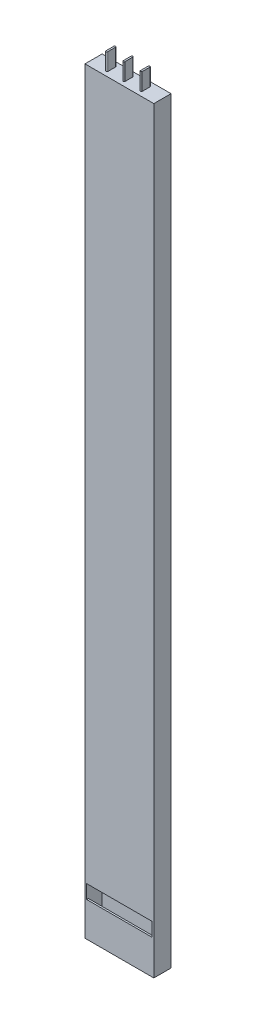
from build123d import *

# Parameters (mm, degrees)
SKETCH2_W           = 40
SKETCH2_H           = 10
BOSS_EXTRUDE2_DEPTH = 440
SKETCH3_W           = 38
SKETCH3_H           = 8
CUT_EXTRUDE1_DEPTH  = 438
BOSS_EXTRUDE4_DEPTH = 10
LPATTERN2_COUNT     = 3
LPATTERN2_PITCH     = 10
SKETCH5_W           = 38
SKETCH5_H           = 8
BOSS_EXTRUDE5_DEPTH = 12
CUT_EXTRUDE2_DEPTH  = 11
LPATTERN3_COUNT     = 3
LPATTERN3_PITCH     = 10
SKETCH7_W           = 38
SKETCH7_H           = 8
CUT_EXTRUDE3_DEPTH  = 5


with BuildPart() as part:
    # Sketch2 → Boss-Extrude2 (new body)
    with BuildSketch(Plane(origin=(0, 0, 0), x_dir=(1, 0, 0), z_dir=(0, 1, 0))):
        Rectangle(SKETCH2_W, SKETCH2_H)
    extrude(amount=BOSS_EXTRUDE2_DEPTH)

    # Sketch3 → Cut-Extrude1 (cut)
    with BuildSketch(Plane(origin=(0, 0, 0), x_dir=(1, 0, 0), z_dir=(0, 1, 0))):
        Rectangle(SKETCH3_W, SKETCH3_H)
    extrude(amount=CUT_EXTRUDE1_DEPTH, mode=Mode.SUBTRACT)

    # Sketch4 → Boss-Extrude4 (add)
    with BuildSketch(Plane(origin=(0, 440, 0), x_dir=(1, 0, 0), z_dir=(0, 1, 0))):
        with BuildLine():
            Line((-10.5, -2.25), (-10.5, 2.25))
            ThreePointArc((-10.5, 2.25), (-10, 2.75), (-9.5, 2.25))
            Line((-9.5, 2.25), (-9.5, -2.25))
            ThreePointArc((-9.5, -2.25), (-10, -2.75), (-10.5, -2.25))
        make_face()
    boss_extrude4 = extrude(amount=BOSS_EXTRUDE4_DEPTH)

    # LPattern2: Boss-Extrude4 ×3
    with Locations(*[(i * LPATTERN2_PITCH, 0, 0) for i in range(1, LPATTERN2_COUNT)]):
        add(boss_extrude4)

    # Sketch5 → Boss-Extrude5 (add)
    with BuildSketch(Plane(origin=(0, 0, 0), x_dir=(-1, 0, 0), z_dir=(0, -1, 0))):
        Rectangle(SKETCH5_W, SKETCH5_H)
    extrude(amount=-BOSS_EXTRUDE5_DEPTH)

    # Sketch6 → Cut-Extrude2 (cut)
    with BuildSketch(Plane.XZ):
        with BuildLine():
            Line((10.5, 2.25), (10.5, -2.25))
            ThreePointArc((10.5, -2.25), (10, -2.75), (9.5, -2.25))
            Line((9.5, -2.25), (9.5, 2.25))
            ThreePointArc((9.5, 2.25), (10, 2.75), (10.5, 2.25))
        make_face()
    cut_extrude2 = extrude(amount=-CUT_EXTRUDE2_DEPTH, mode=Mode.SUBTRACT)

    # LPattern3: Cut-Extrude2 ×3
    with Locations(*[(-i * LPATTERN3_PITCH, 0, 0) for i in range(1, LPATTERN3_COUNT)]):
        add(cut_extrude2, mode=Mode.SUBTRACT)

    # Sketch7 → Cut-Extrude3 (cut)
    with BuildSketch(Plane.XY.offset(5)):
        with Locations((0, 24)):
            Rectangle(SKETCH7_W, SKETCH7_H)
    extrude(amount=-CUT_EXTRUDE3_DEPTH, mode=Mode.SUBTRACT)


solid = part.part
